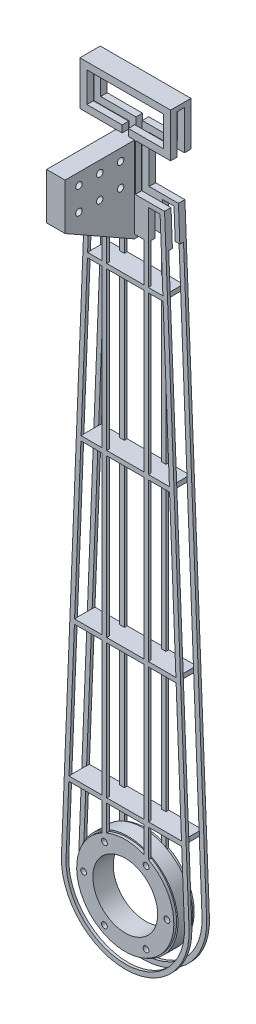
from build123d import *

# Parameters (mm, degrees)
SKETCH1_R                 = 105
SKETCH1_R_2               = 70
BOSS_EXTRUDE1_DEPTH       = 22
BOSS_EXTRUDE1_DEPTH_BACK  = 22
SKETCH2_R                 = 108
SKETCH2_R_2               = 70
BOSS_EXTRUDE2_DEPTH       = 16
BOSS_EXTRUDE2_DEPTH_BACK  = 16
SKETCH4_W                 = 80
SKETCH4_H                 = 290
SKETCH4_H_2               = 340
BOSS_EXTRUDE3_DEPTH       = 6
SKETCH6_W                 = 80
SKETCH6_H                 = 290
SKETCH6_H_2               = 340
BOSS_EXTRUDE4_DEPTH       = 6
SKETCH7_W                 = 163.504684542
SKETCH7_H                 = 10
SKETCH7_W_2               = 191.644954416
SKETCH7_W_3               = 219.785224288
SKETCH7_W_4               = 243.905455608
BOSS_EXTRUDE6_DEPTH       = 38
SKETCH8_W                 = 8
SKETCH8_H                 = 261
SKETCH8_W_2               = 16
SKETCH8_H_2               = 10
SKETCH8_W_3               = 6
BOSS_EXTRUDE7_DEPTH       = 196
CUT_EXTRUDE1_DEPTH        = 7
CUT_EXTRUDE1_DEPTH_BACK   = 39
BOSS_EXTRUDE8_DEPTH       = 6
BOSS_EXTRUDE9_DEPTH       = 6
BOSS_EXTRUDE10_DEPTH      = 20
BOSS_EXTRUDE10_DEPTH_BACK = 20
F_12_0MM_DOWEL_HOLE1_D    = 14
F_12_0MM_DOWEL_HOLE2_D    = 12.5


with BuildPart() as part:
    # Sketch1 → Boss-Extrude1 (new body, two sides)
    with BuildSketch(Plane.XY) as boss_extrude1_sk:
        Circle(SKETCH1_R)
        Circle(SKETCH1_R_2, mode=Mode.SUBTRACT)
    extrude(amount=BOSS_EXTRUDE1_DEPTH)
    extrude(boss_extrude1_sk.sketch, amount=-BOSS_EXTRUDE1_DEPTH_BACK)

    # Sketch2 → Boss-Extrude2 (add, two sides)
    with BuildSketch(Plane.XY) as boss_extrude2_sk:
        Circle(SKETCH2_R)
        Circle(SKETCH2_R_2, mode=Mode.SUBTRACT)
    extrude(amount=BOSS_EXTRUDE2_DEPTH)
    extrude(boss_extrude2_sk.sketch, amount=-BOSS_EXTRUDE2_DEPTH_BACK)

    # Sketch6 → Boss-Extrude4 (add)
    with BuildSketch(Plane(origin=(0, 0, -22), x_dir=(-1, 0, 0), z_dir=(0, 0, -1))):
        with BuildLine():
            Line((-98, 1519), (-98, 1424))
            Line((-98, 1424), (-21.636353824, 1424))
            Line((-21.636353824, 1424), (-21.636353824, 1323))
            Line((-21.636353824, 1323), (-84.926353824, 1323))
            Line((-84.926353824, 1323), (-137.888626074, 5.543175929))
            ThreePointArc((-137.888626074, 5.543175929), (0, -138), (137.888626074, 5.543175929))
            Line((137.888626074, 5.543175929), (84.926353824, 1323))
            Line((84.926353824, 1323), (21.636353824, 1323))
            Line((21.636353824, 1323), (21.636353824, 1424))
            Line((21.636353824, 1424), (98, 1424))
            Line((98, 1424), (98, 1519))
            Line((98, 1519), (-98, 1519))
        make_face()
        Polygon((-50, 453), (-109.892612144, 453), (-121.550723949, 163), (-50, 163), align=None, mode=Mode.SUBTRACT)
        with Locations((0, 308)):
            Rectangle(SKETCH6_W, SKETCH6_H, mode=Mode.SUBTRACT)
        Polygon((109.892612144, 453), (50, 453), (50, 163), (121.550723949, 163), align=None, mode=Mode.SUBTRACT)
        with BuildLine():
            Line((-50, 153), (-121.952727804, 153))
            Line((-121.952727804, 153), (-127.896696649, 5.141496514))
            ThreePointArc((-127.896696649, 5.141496514), (0, -128), (127.896696649, 5.141496514))
            Line((127.896696649, 5.141496514), (121.952727804, 153))
            Line((121.952727804, 153), (50, 153))
            Line((50, 153), (50, 92.330926563))
            ThreePointArc((50, 92.330926563), (45.062669895, 94.838577498), (40, 97.082439195))
            Line((40, 97.082439195), (40, 153))
            Line((40, 153), (-40, 153))
            Line((-40, 153), (-40, 97.082439195))
            ThreePointArc((-40, 97.082439195), (-45.062669895, 94.838577498), (-50, 92.330926563))
            Line((-50, 92.330926563), (-50, 153))
        make_face(mode=Mode.SUBTRACT)
        Polygon((-109.490608289, 463), (-50, 463), (-50, 803), (-95.822477208, 803), align=None, mode=Mode.SUBTRACT)
        Polygon((95.822477208, 803), (50, 803), (50, 463), (109.490608289, 463), align=None, mode=Mode.SUBTRACT)
        Polygon((-50, 1153), (-81.752342271, 1153), (-95.420473352, 813), (-50, 813), align=None, mode=Mode.SUBTRACT)
        with Locations((0, 633)):
            Rectangle(SKETCH6_W, SKETCH6_H_2, mode=Mode.SUBTRACT)
        with Locations((0, 983)):
            Rectangle(SKETCH6_W, SKETCH6_H_2, mode=Mode.SUBTRACT)
        Polygon((81.752342271, 1153), (50, 1153), (50, 813), (95.420473352, 813), align=None, mode=Mode.SUBTRACT)
        Polygon((50, 1163), (81.350338416, 1163), (75.320280586, 1313), (50, 1313), align=None, mode=Mode.SUBTRACT)
        Polygon((-81.350338416, 1163), (-50, 1163), (-50, 1313), (-75.320280586, 1313), align=None, mode=Mode.SUBTRACT)
        Polygon((-40, 1313), (-40, 1163), (40, 1163), (40, 1313), (11.636353824, 1313), (11.636353824, 1434), (88, 1434), (88, 1509), (-88, 1509), (-88, 1434), (-11.636353824, 1434), (-11.636353824, 1313), align=None, mode=Mode.SUBTRACT)
    extrude(amount=-BOSS_EXTRUDE4_DEPTH)



with BuildPart() as body_2:
    # Sketch4 → Boss-Extrude3 (new body)
    with BuildSketch(Plane.XY.offset(22)):
        with BuildLine():
            Line((-84.926353824, 1323), (-137.888626074, 5.543175929))
            ThreePointArc((-137.888626074, 5.543175929), (0, -138), (137.888626074, 5.543175929))
            Line((137.888626074, 5.543175929), (84.926353824, 1323))
            Line((84.926353824, 1323), (21.636353824, 1323))
            Line((21.636353824, 1323), (21.636353824, 1424))
            Line((21.636353824, 1424), (98, 1424))
            Line((98, 1424), (98, 1519))
            Line((98, 1519), (-98, 1519))
            Line((-98, 1519), (-98, 1424))
            Line((-98, 1424), (-21.636353824, 1424))
            Line((-21.636353824, 1424), (-21.636353824, 1323))
            Line((-21.636353824, 1323), (-84.926353824, 1323))
        make_face()
        Polygon((-121.550723949, 163), (-109.892612144, 453), (-50, 453), (-50, 163), align=None, mode=Mode.SUBTRACT)
        Polygon((-109.490608289, 463), (-95.822477208, 803), (-50, 803), (-50, 463), align=None, mode=Mode.SUBTRACT)
        with Locations((0, 308)):
            Rectangle(SKETCH4_W, SKETCH4_H, mode=Mode.SUBTRACT)
        with Locations((0, 633)):
            Rectangle(SKETCH4_W, SKETCH4_H_2, mode=Mode.SUBTRACT)
        with BuildLine():
            ThreePointArc((127.896696649, 5.141496514), (0, -128), (-127.896696649, 5.141496514))
            Line((-127.896696649, 5.141496514), (-121.952727804, 153))
            Line((-121.952727804, 153), (-50, 153))
            Line((-50, 153), (-50, 92.330926563))
            ThreePointArc((-50, 92.330926563), (-45.062669895, 94.838577498), (-40, 97.082439195))
            Line((-40, 97.082439195), (-40, 153))
            Line((-40, 153), (40, 153))
            Line((40, 153), (40, 97.082439195))
            ThreePointArc((40, 97.082439195), (45.062669895, 94.838577498), (50, 92.330926563))
            Line((50, 92.330926563), (50, 153))
            Line((50, 153), (121.952727804, 153))
            Line((121.952727804, 153), (127.896696649, 5.141496514))
        make_face(mode=Mode.SUBTRACT)
        Polygon((121.550723949, 163), (50, 163), (50, 453), (109.892612144, 453), align=None, mode=Mode.SUBTRACT)
        Polygon((95.822477208, 803), (109.490608289, 463), (50, 463), (50, 803), align=None, mode=Mode.SUBTRACT)
        Polygon((-95.420473352, 813), (-81.752342271, 1153), (-50, 1153), (-50, 813), align=None, mode=Mode.SUBTRACT)
        with Locations((0, 983)):
            Rectangle(SKETCH4_W, SKETCH4_H_2, mode=Mode.SUBTRACT)
        Polygon((-81.350338416, 1163), (-75.320280586, 1313), (-50, 1313), (-50, 1163), align=None, mode=Mode.SUBTRACT)
        Polygon((-40, 1313), (-11.636353824, 1313), (-11.636353824, 1434), (-88, 1434), (-88, 1509), (88, 1509), (88, 1434), (11.636353824, 1434), (11.636353824, 1313), (40, 1313), (40, 1163), (-40, 1163), align=None, mode=Mode.SUBTRACT)
        Polygon((81.752342271, 1153), (95.420473352, 813), (50, 813), (50, 1153), align=None, mode=Mode.SUBTRACT)
        Polygon((50, 1313), (75.320280586, 1313), (81.350338416, 1163), (50, 1163), align=None, mode=Mode.SUBTRACT)
    extrude(amount=-BOSS_EXTRUDE3_DEPTH)


with BuildPart() as part_1:
    add(part.part)

    add(body_2.part)  # Boss-Extrude6 merges body 2
    # Sketch7 → Boss-Extrude6 (add)
    with BuildSketch(Plane(origin=(0, 0, -16), x_dir=(-1, 0, 0), z_dir=(0, 0, -1))):
        with Locations((0, 1158)):
            Rectangle(SKETCH7_W, SKETCH7_H)
        with Locations((0, 808)):
            Rectangle(SKETCH7_W_2, SKETCH7_H)
        with Locations((0, 458)):
            Rectangle(SKETCH7_W_3, SKETCH7_H)
        with Locations((0, 158)):
            Rectangle(SKETCH7_W_4, SKETCH7_H)
    extrude(amount=-BOSS_EXTRUDE6_DEPTH)

    # Sketch8 → Boss-Extrude7 (add)
    with BuildSketch(Plane(origin=(98, 0, 0), x_dir=(0, 0, -1), z_dir=(1, 0, 0))):
        Polygon((-8, 1509), (-16, 1509), (-16, 1424), (-16, 1248), (-8, 1248), align=None)
        with Locations((12, 1378.5)):
            Rectangle(SKETCH8_W, SKETCH8_H)
        with Locations((0, 1514)):
            Rectangle(SKETCH8_W_2, SKETCH8_H_2)
        with Locations((-12, 1514)):
            Rectangle(SKETCH8_W, SKETCH8_H_2)
        with Locations((12, 1514)):
            Rectangle(SKETCH8_W, SKETCH8_H_2)
        with Locations((19, 1514)):
            Rectangle(SKETCH8_W_3, SKETCH8_H_2)
        with Locations((-19, 1514)):
            Rectangle(SKETCH8_W_3, SKETCH8_H_2)
    extrude(amount=-BOSS_EXTRUDE7_DEPTH)

    # Sketch10 → Cut-Extrude1 (cut, two sides)
    with BuildSketch(Plane.XY.offset(16)) as cut_extrude1_sk:
        Polygon((-77.933305646, 1248), (-50, 1248), (-50, 1313), (-75.320280586, 1313), align=None)
        Polygon((-98, 1424), (-98, 1248), (-87.941382739, 1248), (-84.926353824, 1323), (-21.636353824, 1323), (-21.636353824, 1424), align=None)
        Polygon((50, 1313), (50, 1248), (77.933305646, 1248), (75.320280586, 1313), align=None)
        Polygon((98, 1248), (98, 1424), (21.636353824, 1424), (21.636353824, 1323), (84.926353824, 1323), (87.941382739, 1248), align=None)
        Polygon((-6.636353824, 1439), (-6.636353824, 1248), (6.636353824, 1248), (6.636353824, 1439), (83, 1439), (83, 1504), (-83, 1504), (-83, 1439), align=None)
    extrude(amount=CUT_EXTRUDE1_DEPTH, mode=Mode.SUBTRACT)
    extrude(cut_extrude1_sk.sketch, amount=-CUT_EXTRUDE1_DEPTH_BACK, mode=Mode.SUBTRACT)

    # Sketch11 → Boss-Extrude8 (add)
    with BuildSketch(Plane.XY.offset(16)):
        Polygon((83, 1439), (6.636353824, 1439), (6.636353824, 1248), (40, 1248), (40, 1313), (11.636353824, 1313), (11.636353824, 1434), (88, 1434), (88, 1509), (-88, 1509), (-88, 1434), (-11.636353824, 1434), (-11.636353824, 1313), (-40, 1313), (-40, 1248), (-6.636353824, 1248), (-6.636353824, 1439), (-83, 1439), (-83, 1504), (83, 1504), align=None)
    extrude(amount=BOSS_EXTRUDE8_DEPTH)

    # Sketch12 → Boss-Extrude9 (add)
    with BuildSketch(Plane(origin=(0, 0, -16), x_dir=(-1, 0, 0), z_dir=(0, 0, -1))):
        Polygon((-40, 1313), (-40, 1248), (-6.636353824, 1248), (-6.636353824, 1439), (-83, 1439), (-83, 1504), (83, 1504), (83, 1439), (6.636353824, 1439), (6.636353824, 1248), (40, 1248), (40, 1313), (11.636353824, 1313), (11.636353824, 1434), (88, 1434), (88, 1509), (-88, 1509), (-88, 1434), (-11.636353824, 1434), (-11.636353824, 1313), align=None)
    extrude(amount=BOSS_EXTRUDE9_DEPTH)

    # Sketch13 → Boss-Extrude10 (add, two sides)
    with BuildSketch(Plane(origin=(0, 0, 0), x_dir=(0, 0, -1), z_dir=(1, 0, 0))) as boss_extrude10_sk:
        Polygon((-172, 1324), (-22, 1238.998775891), (-16, 1238.998775891), (-16, 1248), (-8, 1248), (-8, 1424), (-22, 1424), (-172, 1424), align=None)
    extrude(amount=BOSS_EXTRUDE10_DEPTH)
    extrude(boss_extrude10_sk.sketch, amount=-BOSS_EXTRUDE10_DEPTH_BACK)

    # 12.0mm Dowel Hole1 (through all)
    with Locations(Plane(origin=(20, 0, 0), x_dir=(0, 0, -1), z_dir=(1, 0, 0))):
        with Locations((-142, 1399), (-142, 1349), (-97, 1399), (-52, 1399), (-52, 1349), (-97, 1349)):
            Hole(F_12_0MM_DOWEL_HOLE1_D / 2)

    # 12.0mm Dowel Hole2 (through all)
    with Locations(Plane.XY.offset(22)):
        with Locations((45, 77.942286341), (90, 0), (45, -77.942286341), (-45, -77.942286341), (-90, 0), (-45, 77.942286341)):
            Hole(F_12_0MM_DOWEL_HOLE2_D / 2)


solid = part_1.part
